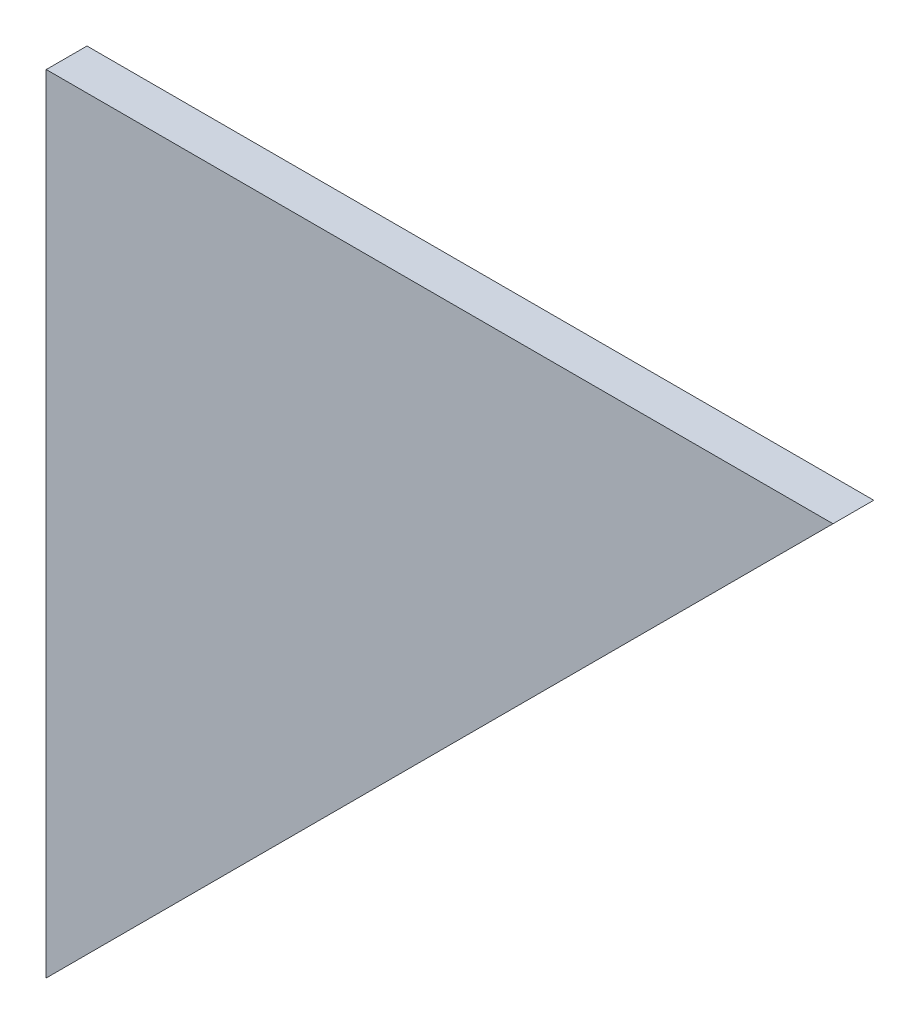
from build123d import *

# Parameters (mm, degrees)
BOSS_EXTRUDE1_DEPTH = 1.5


with BuildPart() as part:
    # Sketch1 → Boss-Extrude1 (new body, symmetric)
    with BuildSketch(Plane.XY.offset(113.704878)):
        Polygon((49.638102576, -107.572775552), (107.572775552, -49.638102576), (49.638102576, -49.638102576), align=None)
    extrude(amount=BOSS_EXTRUDE1_DEPTH, both=True)


solid = part.part
